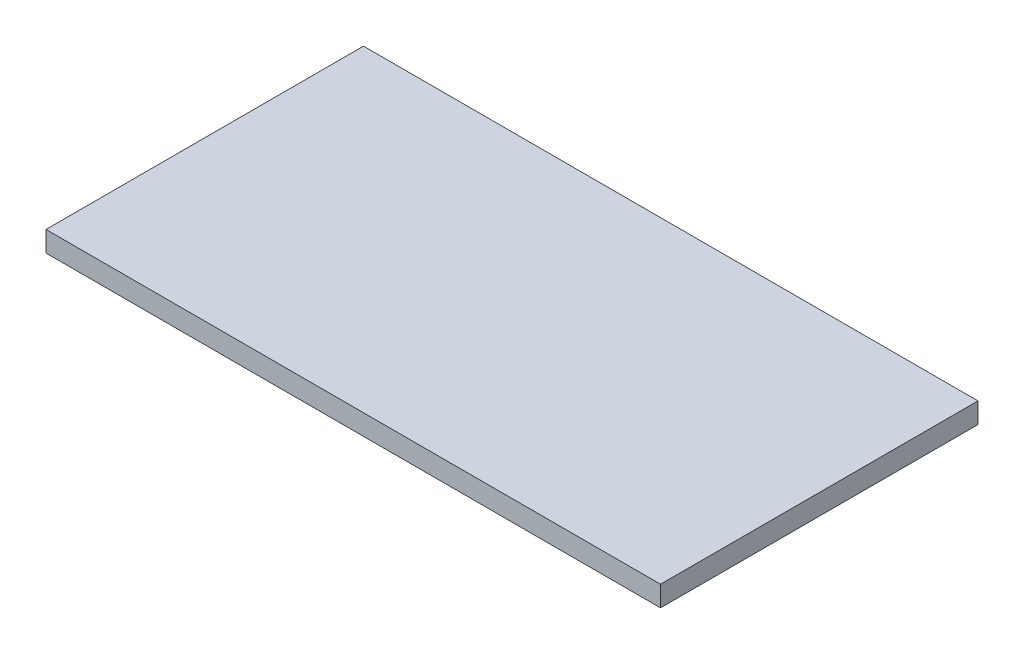
from build123d import *

# Parameters (mm, degrees)
SKETCH1_W           = 60
SKETCH1_H           = 31
BOSS_EXTRUDE2_DEPTH = 2


with BuildPart() as part:
    # Sketch1 → Boss-Extrude2 (new body)
    with BuildSketch(Plane(origin=(0, 0, 0), x_dir=(1, 0, 0), z_dir=(0, 1, 0))):
        with Locations((30, -15.5)):
            Rectangle(SKETCH1_W, SKETCH1_H)
    extrude(amount=-BOSS_EXTRUDE2_DEPTH)


solid = part.part
